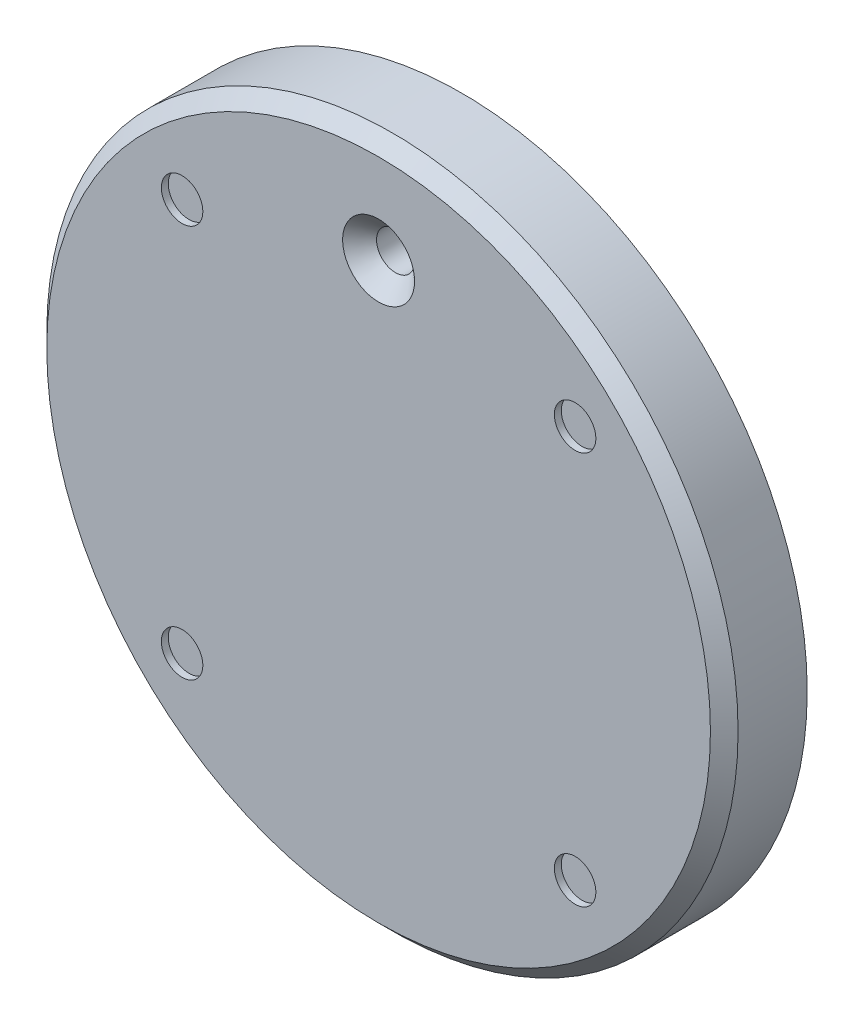
from build123d import *

# Parameters (mm, degrees)
SKETCH2_R                                       = 50
BOSS_EXTRUDE1_DEPTH                             = 12
CSK_FOR_M5_FLAT_HEAD_MACHINE_SCREW1_D           = 5.5
CSK_FOR_M5_FLAT_HEAD_MACHINE_SCREW1_DEPTH       = 12
CSK_FOR_M5_FLAT_HEAD_MACHINE_SCREW1_CSINK_D     = 10.4
CSK_FOR_M5_FLAT_HEAD_MACHINE_SCREW1_CSINK_ANGLE = 90
SKETCH6_R                                       = 3
CUT_EXTRUDE1_DEPTH                              = 1
CHAMFER1_SIZE                                   = 2


with BuildPart() as part:
    # Sketch2 → Boss-Extrude1 (new body)
    with BuildSketch(Plane.XY):
        Circle(SKETCH2_R)
    extrude(amount=BOSS_EXTRUDE1_DEPTH)

    # CSK for M5 Flat Head Machine Screw1
    with Locations(Plane.XY.offset(12)):
        with Locations((0, 35)):
            CounterSinkHole(CSK_FOR_M5_FLAT_HEAD_MACHINE_SCREW1_D / 2, CSK_FOR_M5_FLAT_HEAD_MACHINE_SCREW1_CSINK_D / 2, depth=CSK_FOR_M5_FLAT_HEAD_MACHINE_SCREW1_DEPTH, counter_sink_angle=CSK_FOR_M5_FLAT_HEAD_MACHINE_SCREW1_CSINK_ANGLE)

    # Sketch6 → Cut-Extrude1 (cut)
    with BuildSketch(Plane.XY.offset(12)):
        with Locations((-28.425692604, 28.425692604)):
            Circle(SKETCH6_R)
        with Locations((28.425692604, 28.425692604)):
            Circle(SKETCH6_R)
        with Locations((28.425692604, -28.425692604)):
            Circle(SKETCH6_R)
        with Locations((-28.425692604, -28.425692604)):
            Circle(SKETCH6_R)
    extrude(amount=-CUT_EXTRUDE1_DEPTH, mode=Mode.SUBTRACT)

    # Chamfer1
    chamfer1_edges = [part.edges().sort_by_distance(p)[0] for p in [
        (-50, 0, 12),
    ]]
    chamfer(chamfer1_edges, length=CHAMFER1_SIZE)


solid = part.part
